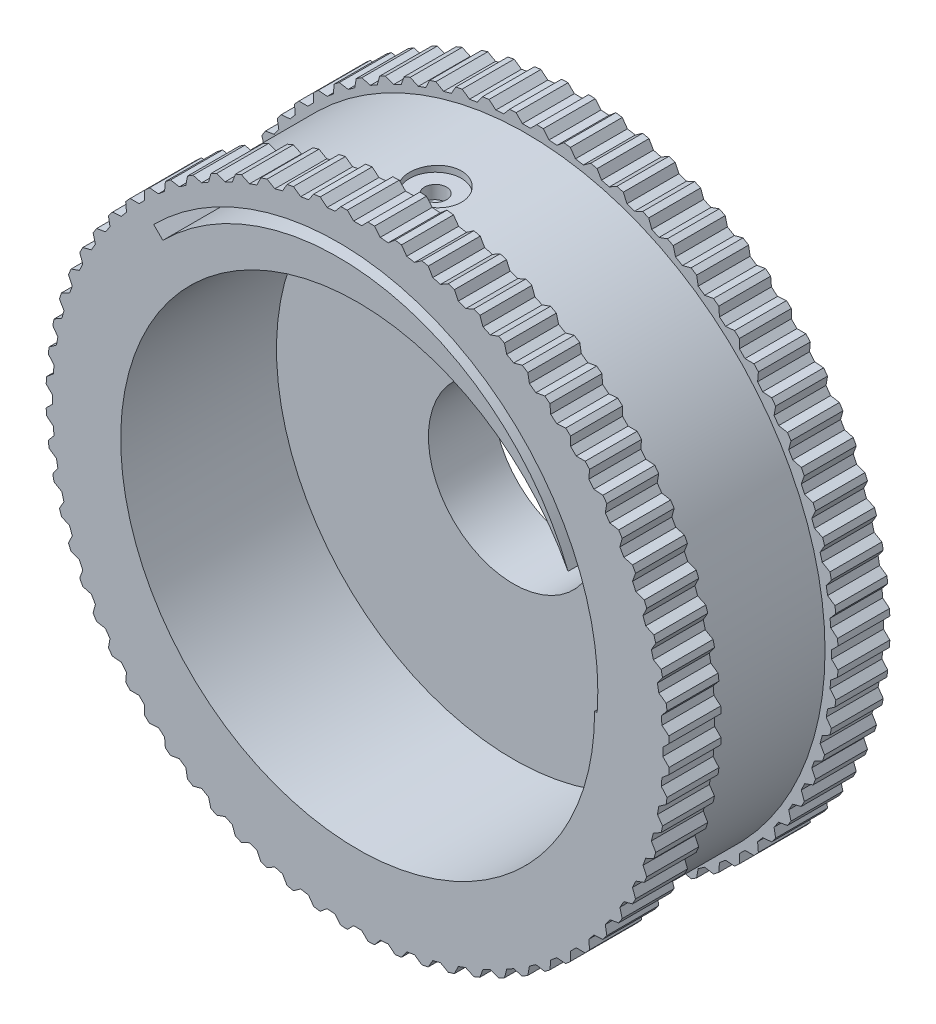
from build123d import *

# Parameters (mm, degrees)
SKETCH1_R                  = 24
SKETCH1_R_2                = 6.55
MAIN_DEPTH                 = 8.5
SKETCH2_R                  = 18.25
FORSPRINGHOLE_DEPTH        = 12
TEETH_DEPTH                = 18
TEETHCIRCULARPATTERN_COUNT = 72
SKETCH4_R                  = 25
SKETCH4_R_2                = 23
REDUCESURFACECONTACT_DEPTH = 4.5
SPRINGHOLE_DEPTH           = 12
SKETCH7_R                  = 0.85
SPRINGFIXINGHOLE_DEPTH     = 10
SKETCH8_R                  = 2
HEADOFSCREW_DEPTH          = 1.5


with BuildPart() as part:
    # Sketch1 → Main (new body, symmetric)
    with BuildSketch(Plane.XY):
        Circle(SKETCH1_R)
        Circle(SKETCH1_R_2, mode=Mode.SUBTRACT)
    extrude(amount=MAIN_DEPTH, both=True)

    # Sketch2 → ForSpringHole (cut)
    with BuildSketch(Plane.XY.offset(8.5)):
        Circle(SKETCH2_R)
    extrude(amount=-FORSPRINGHOLE_DEPTH, mode=Mode.SUBTRACT)

    # Sketch3 → Teeth (cut, through all)
    with BuildSketch(Plane.XY.offset(8.5)):
        with BuildLine():
            Line((-0.794478334, 23.986846483), (-0.307631851, 23.5))
            Line((-0.307631851, 23.5), (0.307631851, 23.5))
            Line((0.307631851, 23.5), (0.794478334, 23.986846483))
            ThreePointArc((0.794478334, 23.986846483), (0, 24.431780726), (-0.794478334, 23.986846483))
        make_face()
    teeth = extrude(amount=-TEETH_DEPTH, mode=Mode.SUBTRACT)

    # TeethCircularPattern: Teeth ×72 about axis
    teethcircularpattern_axis = Axis((0, 0, 0), (0, 0, 1))
    for i in range(1, TEETHCIRCULARPATTERN_COUNT):
        add(teeth.rotate(teethcircularpattern_axis, i * 360 / TEETHCIRCULARPATTERN_COUNT), mode=Mode.SUBTRACT)

    # Sketch4 → ReduceSurfaceContact (cut, symmetric)
    with BuildSketch(Plane.XY):
        Circle(SKETCH4_R)
        Circle(SKETCH4_R_2, mode=Mode.SUBTRACT)
    extrude(amount=REDUCESURFACECONTACT_DEPTH, both=True, mode=Mode.SUBTRACT)

    # Sketch6 → SpringHole (cut)
    with BuildSketch(Plane.XY.offset(8.5)):
        with BuildLine():
            Line((-15.710183625, 15.573758608), (-15, 14.869742117))
            ThreePointArc((-15, 14.869742117), (2.361161317, 20.103532932), (16.205537496, 8.39303607))
            ThreePointArc((16.205537496, 8.39303607), (17.721643916, 4.359568432), (18.249810962, 0.083065253))
            Line((18.249810962, 0.083065253), (18.449808891, 0.083975557))
            ThreePointArc((18.449808891, 0.083975557), (6.75948965, 19.714851927), (-15.710183625, 15.573758608))
        make_face()
    extrude(amount=-SPRINGHOLE_DEPTH, mode=Mode.SUBTRACT)

    # Sketch7 → SpringFixingHole (cut)
    with BuildSketch(Plane(origin=(0, 24, 0), x_dir=(1, 0, 0), z_dir=(0, 1, 0))):
        with Locations((0, -2.5)):
            Circle(SKETCH7_R)
    extrude(amount=-SPRINGFIXINGHOLE_DEPTH, mode=Mode.SUBTRACT)

    # Sketch8 → HeadOfScrew (cut)
    with BuildSketch(Plane(origin=(0, 24, 0), x_dir=(1, 0, 0), z_dir=(0, 1, 0))):
        with Locations((0, -2.5)):
            Circle(SKETCH8_R)
    extrude(amount=-HEADOFSCREW_DEPTH, mode=Mode.SUBTRACT)


solid = part.part
